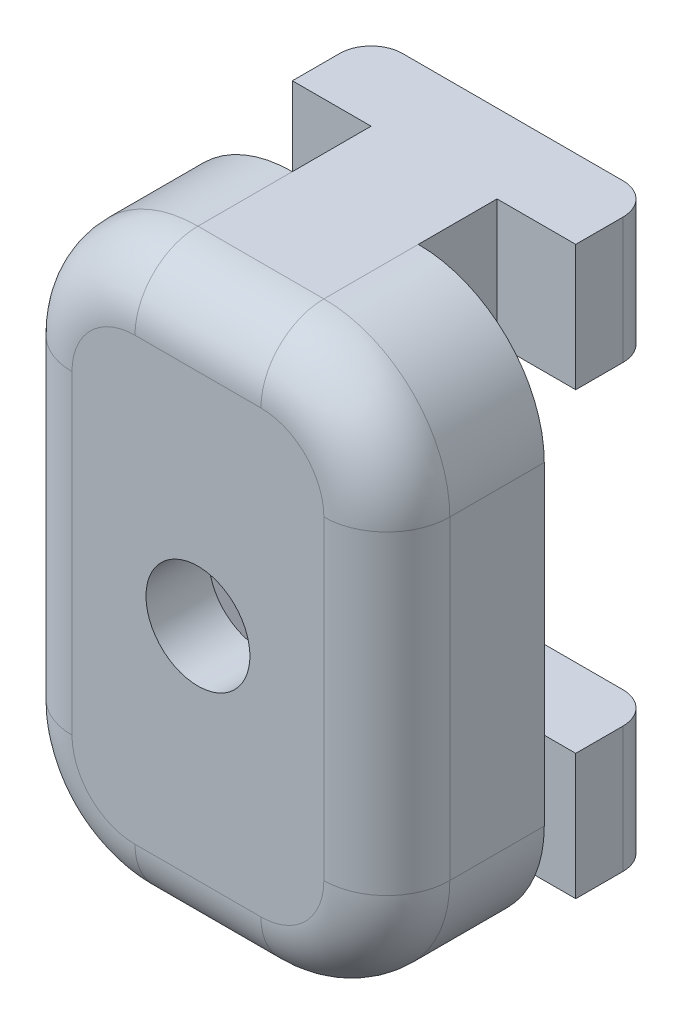
from build123d import *

# Parameters (mm, degrees)
BOSS_EXTRU_3_DEPTH      = 4
ESQUISSE3_W             = 12
ESQUISSE3_H             = 5
BOSS_EXTRU_4_DEPTH      = 5
ENL_V_MAT_EXTRU_1_REACH = 7
ESQUISSE4_R             = 1.65
ENL_V_MAT_EXTRU_2_DEPTH = 3
CONG_1_R                = 4
CONG_2_R                = 2


with BuildPart() as part:
    # Esquisse2 → Boss.-Extru.3 (new body)
    with BuildSketch(Plane(origin=(0, 0, 0), x_dir=(1, 0, 0), z_dir=(0, 1, 0))):
        with BuildLine():
            Line((11.568725398, 38.128215269), (18.568725398, 38.128215269))
            ThreePointArc((18.568725398, 38.128215269), (19.275832179, 37.83532205), (19.568725398, 37.128215269))
            Line((19.568725398, 37.128215269), (19.568725398, 35.628215269))
            Line((19.568725398, 35.628215269), (17.068725398, 35.628215269))
            Line((17.068725398, 35.628215269), (17.068725398, 33.128215269))
            Line((17.068725398, 33.128215269), (21.068725398, 33.128215269))
            Line((21.068725398, 33.128215269), (21.068725398, 28.128215269))
            Line((21.068725398, 28.128215269), (9.068725398, 28.128215269))
            Line((9.068725398, 28.128215269), (9.068725398, 33.128215269))
            Line((9.068725398, 33.128215269), (13.068725398, 33.128215269))
            Line((13.068725398, 33.128215269), (13.068725398, 35.628215269))
            Line((13.068725398, 35.628215269), (10.568725398, 35.628215269))
            Line((10.568725398, 35.628215269), (10.568725398, 37.128215269))
            ThreePointArc((10.568725398, 37.128215269), (10.861618616, 37.83532205), (11.568725398, 38.128215269))
        make_face()
    extrude(amount=BOSS_EXTRU_3_DEPTH)

    # Esquisse3 → Boss.-Extru.4 (add)
    with BuildSketch(Plane(origin=(0, 4, 0), x_dir=(1, 0, 0), z_dir=(0, 1, 0))):
        with Locations((15.068725398, 30.628215269)):
            Rectangle(ESQUISSE3_W, ESQUISSE3_H)
    extrude(amount=BOSS_EXTRU_4_DEPTH)

    # Symétrie1: part across plane


with BuildPart() as part_1:
    add(part.part)
    add(part.part.mirror(Plane.ZX.offset(9)))

    # Esquisse4 → Enlèv. mat.-Extru.1 (cut, up to next)
    with BuildSketch(Plane(origin=(0, 0, -33.128215269), x_dir=(-1, 0, 0), z_dir=(0, 0, -1)), mode=Mode.PRIVATE) as enl_v_mat_extru_1_sk1:
        with Locations((-15.068725398, 9)):
            Circle(ESQUISSE4_R)
    enl_v_mat_extru_1_tool1 = extrude(enl_v_mat_extru_1_sk1.sketch, amount=-ENL_V_MAT_EXTRU_1_REACH, mode=Mode.PRIVATE) & part_1.part
    add(enl_v_mat_extru_1_tool1.solids().sort_by_distance((15.068725, 9, -33.128215))[0], mode=Mode.SUBTRACT)

    # Esquisse5 → Enlèv. mat.-Extru.2 (cut)
    with BuildSketch(Plane(origin=(0, 0, -33.128215269), x_dir=(-1, 0, 0), z_dir=(0, 0, -1))):
        Polygon((-13.42327713, 11.85), (-16.714173665, 11.85), (-18.359621932, 9), (-16.714173665, 6.15), (-13.42327713, 6.15), (-11.777828863, 9), align=None)
    extrude(amount=-ENL_V_MAT_EXTRU_2_DEPTH, mode=Mode.SUBTRACT)

    # Congé1
    cong_1_edges = [part_1.edges().sort_by_distance(p)[0] for p in [
        (9.068725398, 0, -30.628215269),
        (9.068725398, 18, -30.628215269),
        (21.068725398, 18, -30.628215269),
        (21.068725398, 0, -30.628215269),
    ]]
    fillet(cong_1_edges, radius=CONG_1_R)

    # Congé2
    cong_2_edges = [part_1.edges().sort_by_distance(p)[0] for p in [
        (9.068725398, 9, -28.128215269),
        (15.068725398, 0, -28.128215269),
        (21.068725398, 9, -28.128215269),
        (15.068725398, 18, -28.128215269),
        (19.897152522, 16.828427125, -28.128215269),
        (19.897152522, 1.171572875, -28.128215269),
        (10.240298273, 16.828427125, -28.128215269),
        (10.240298273, 1.171572875, -28.128215269),
    ]]
    fillet(cong_2_edges, radius=CONG_2_R)


solid = part_1.part
